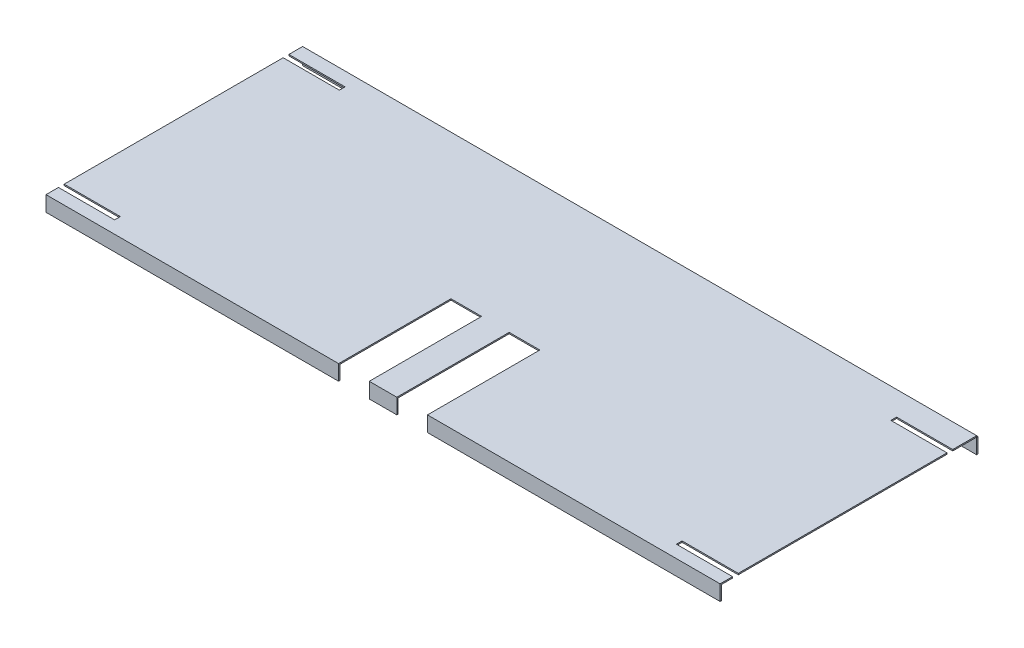
from build123d import *

# Parameters (mm, degrees)
SKETCH1_W           = 838.2
SKETCH1_H           = 317.5
BOSS_EXTRUDE1_DEPTH = 1.6002
SKETCH3_W           = 838.2
SKETCH3_H           = 19.05
BOSS_EXTRUDE2_DEPTH = 1.6002
CUT_EXTRUDE1_REACH  = 21.05
SKETCH2_W           = 38.1
SKETCH2_H           = 139.7
SKETCH4_W           = 838.2
SKETCH4_H           = 19.05
BOSS_EXTRUDE3_DEPTH = 1.6002
SKETCH5_W           = 69.85
SKETCH5_H           = 7.112
CUT_EXTRUDE2_DEPTH  = 1.6002


with BuildPart() as part:
    # Sketch1 → Boss-Extrude1 (new body)
    with BuildSketch(Plane(origin=(0, 0, 0), x_dir=(1, 0, 0), z_dir=(0, 1, 0))):
        with Locations((419.1, -158.75)):
            Rectangle(SKETCH1_W, SKETCH1_H)
    extrude(amount=BOSS_EXTRUDE1_DEPTH)

    # Sketch3 → Boss-Extrude2 (add)
    with BuildSketch(Plane.XY.offset(317.5)):
        with Locations((419.1, -7.9248)):
            Rectangle(SKETCH3_W, SKETCH3_H)
    extrude(amount=BOSS_EXTRUDE2_DEPTH)

    # Sketch2 → Cut-Extrude1 (cut, up to next)
    with BuildSketch(Plane(origin=(0, 1.6002, 0), x_dir=(1, 0, 0), z_dir=(0, 1, 0)), mode=Mode.PRIVATE) as cut_extrude1_sk1:
        with Locations((382.905, -249.2502)):
            Rectangle(SKETCH2_W, SKETCH2_H)
    cut_extrude1_tool1 = extrude(cut_extrude1_sk1.sketch, amount=-CUT_EXTRUDE1_REACH, mode=Mode.PRIVATE) & part.part
    add(cut_extrude1_tool1.solids().sort_by_distance((382.905, 1.6002, 249.2502))[0], mode=Mode.SUBTRACT)
    # Sketch2 → Cut-Extrude1 (cut, up to next)
    with BuildSketch(Plane(origin=(0, 1.6002, 0), x_dir=(1, 0, 0), z_dir=(0, 1, 0)), mode=Mode.PRIVATE) as cut_extrude1_sk2:
        with Locations((455.295, -249.2502)):
            Rectangle(SKETCH2_W, SKETCH2_H)
    cut_extrude1_tool2 = extrude(cut_extrude1_sk2.sketch, amount=-CUT_EXTRUDE1_REACH, mode=Mode.PRIVATE) & part.part
    add(cut_extrude1_tool2.solids().sort_by_distance((455.295, 1.6002, 249.2502))[0], mode=Mode.SUBTRACT)

    # Sketch5 → Cut-Extrude2 (cut)
    with BuildSketch(Plane(origin=(0, 1.6002, 0), x_dir=(1, 0, 0), z_dir=(0, 1, 0))):
        with Locations((34.925, -20.6502)):
            Rectangle(SKETCH5_W, SKETCH5_H)
        with Locations((34.925, -300.0502)):
            Rectangle(SKETCH5_W, SKETCH5_H)
        with Locations((803.275, -33.3502)):
            Rectangle(SKETCH5_W, SKETCH5_H)
        with Locations((803.275, -300.0502)):
            Rectangle(SKETCH5_W, SKETCH5_H)
    extrude(amount=-CUT_EXTRUDE2_DEPTH, mode=Mode.SUBTRACT)


with BuildPart() as body_2:
    # Sketch4 → Boss-Extrude3 (new body)
    with BuildSketch(Plane(origin=(0, 0, 0), x_dir=(-1, 0, 0), z_dir=(0, 0, -1))):
        with Locations((-419.1, -9.525)):
            Rectangle(SKETCH4_W, SKETCH4_H)
    extrude(amount=BOSS_EXTRUDE3_DEPTH)


solid = Compound([part.part, body_2.part])
